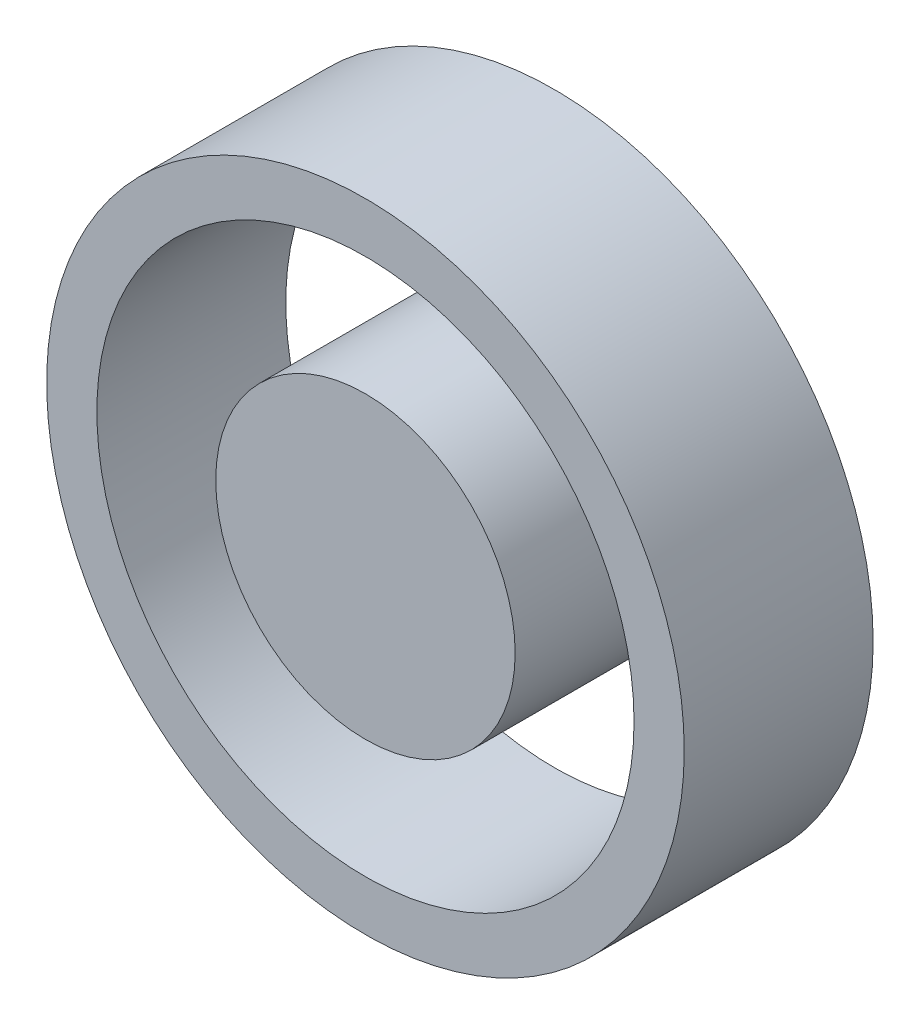
from build123d import *

# Parameters (mm, degrees)
SKETCH1_R             = 85.725
SKETCH1_R_2           = 72.23125
BOSS_EXTRUDE1_DEPTH   = 50.8
SKETCH1_R_3           = 40.259
BOSS_EXTRUDE1_2_DEPTH = 50.8


with BuildPart() as part:
    # Sketch1 → Boss-Extrude1 (new body)
    with BuildSketch(Plane.XY):
        Circle(SKETCH1_R)
        Circle(SKETCH1_R_2, mode=Mode.SUBTRACT)
    extrude(amount=BOSS_EXTRUDE1_DEPTH)


with BuildPart() as body_2:
    # Sketch1 → Boss-Extrude1 2 (new body)
    with BuildSketch(Plane.XY):
        Circle(SKETCH1_R_3)
    extrude(amount=BOSS_EXTRUDE1_2_DEPTH)


solid = Compound([part.part, body_2.part])
